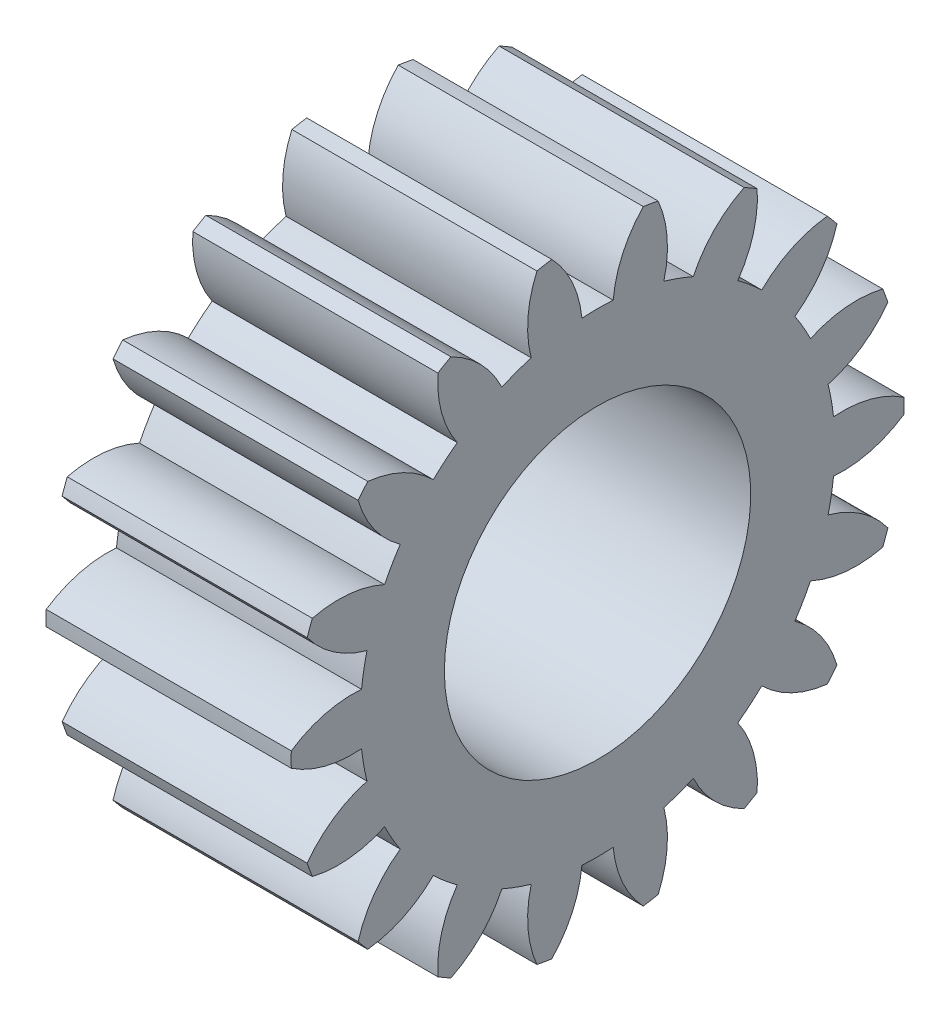
from build123d import *

# Parameters (mm, degrees)
BASPROSKE_W     = 8
BASPROSKE_H     = 10
TOOTHCUT_DEPTH  = 17.248076809
TEETHCUTS_COUNT = 18
TEETHCUTS_ANGLE = 340
BORSKE_R        = 5
BORE_DEPTH      = 50.0000508


with BuildPart() as part:
    # BasProSke → Base-Revolve (revolve)
    with BuildSketch(Plane(origin=(0, 0, 0), x_dir=(1, 0, 0), z_dir=(0, 1, 0)), mode=Mode.PRIVATE) as base_revolve_sk:
        with Locations((4, 5)):
            Rectangle(BASPROSKE_W, BASPROSKE_H)
    revolve(base_revolve_sk.sketch.rotate(Axis((-10, 0, 0), (1, 0, 0)), 180), axis=Axis((-10, 0, 0), (1, 0, 0)))

    # TooCutSke → ToothCut (cut, through all)
    with BuildSketch(Plane(origin=(0, 0, 0), x_dir=(0, 0, -1), z_dir=(1, 0, 0))):
        with BuildLine():
            ThreePointArc((0.510641536, 7.732156635), (0, 7.749), (-0.510641536, 7.732156635))
            ThreePointArc((-0.510641536, 7.732156635), (-0.82619259, 8.907320741), (-1.515208602, 9.910236529))
            ThreePointArc((-1.515208602, 9.910236529), (0, 10.0254), (1.515208602, 9.910236529))
            ThreePointArc((1.515208602, 9.910236529), (0.82619259, 8.907320741), (0.510641536, 7.732156635))
        make_face()
    toothcut = extrude(amount=TOOTHCUT_DEPTH, mode=Mode.SUBTRACT)

    # TeethCuts: ToothCut ×18 about axis
    teethcuts_axis = Axis((-10, 0, 0), (1, 0, 0))
    for i in range(1, TEETHCUTS_COUNT):
        add(toothcut.rotate(teethcuts_axis, i * TEETHCUTS_ANGLE / (TEETHCUTS_COUNT - 1)), mode=Mode.SUBTRACT)

    # BorSke → Bore (cut, symmetric)
    with BuildSketch(Plane(origin=(0, 0, 0), x_dir=(0, 0, -1), z_dir=(1, 0, 0))):
        with Locations(Location((0, 0, 0), (0, 0, 180))):
            Circle(BORSKE_R)
    extrude(amount=BORE_DEPTH, both=True, mode=Mode.SUBTRACT)


solid = part.part
